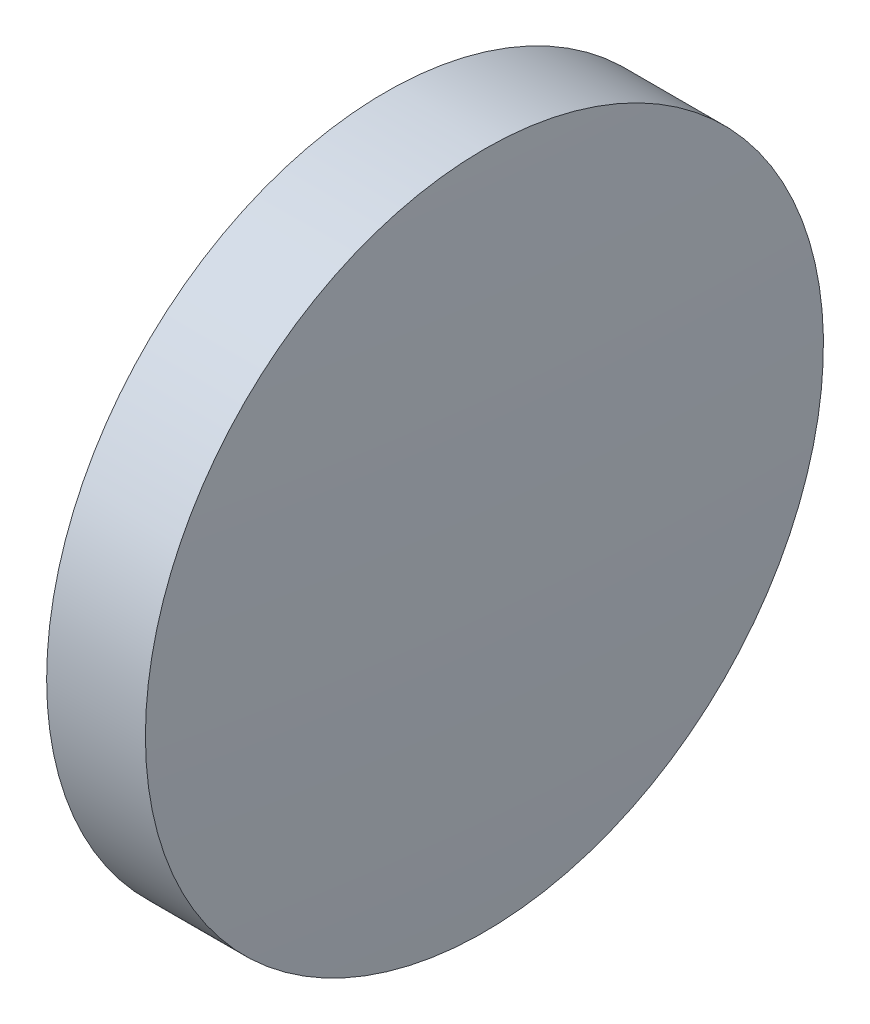
from build123d import *


with BuildPart() as part:
    # 草图1 → 旋转1 (revolve)
    with BuildSketch(Plane.XY):
        with BuildLine():
            Line((544.395654624, 475.374178646), (544.395654624, 488.074178646))
            Line((544.395654624, 488.074178646), (548.095654624, 488.074178646))
            ThreePointArc((548.095654624, 488.074178646), (548.320644164, 481.725950053), (548.395654624, 475.374178646))
            Line((548.395654624, 475.374178646), (544.395654624, 475.374178646))
        make_face()
    revolve(axis=Axis((538.765758572, 475.374178646, 0), (1, 0, 0)))


solid = part.part
